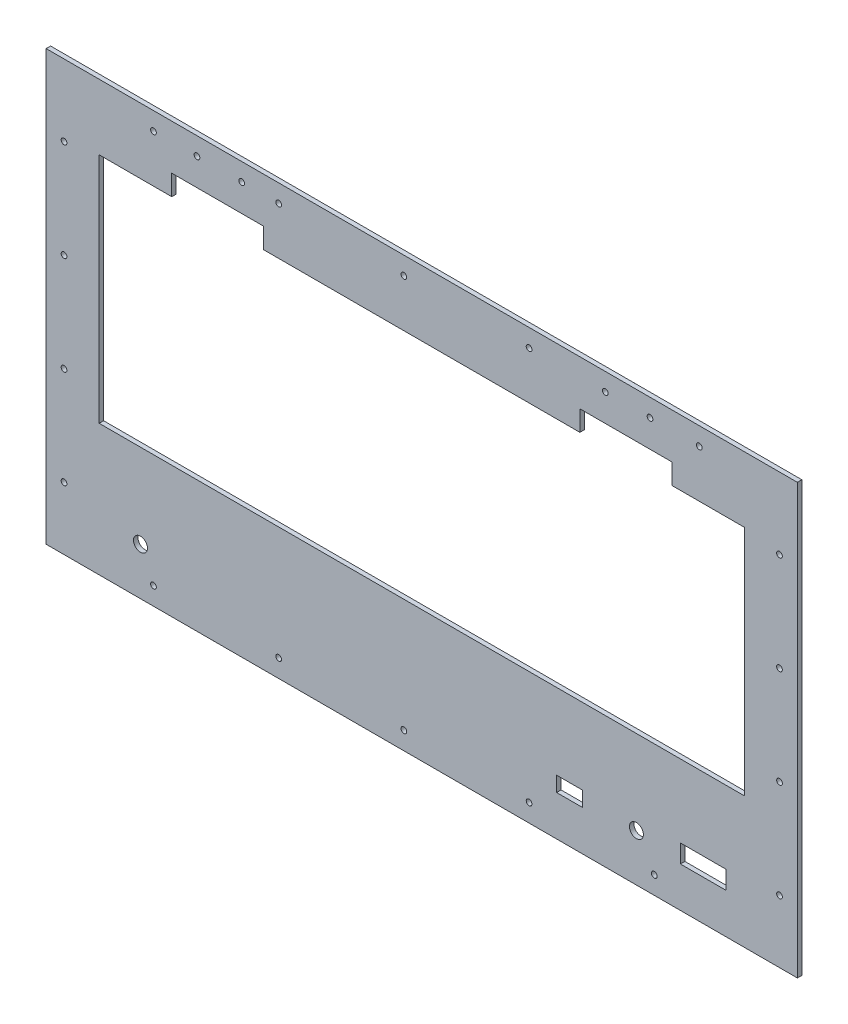
from build123d import *

# Parameters (mm, degrees)
SKETCH1_W           = 533.4
SKETCH1_H           = 304.8
BOSS_EXTRUDE1_DEPTH = 3.175
SKETCH5_R           = 2.032
CUT_EXTRUDE4_DEPTH  = 4.175
SKETCH6_R           = 2.032
CUT_EXTRUDE5_DEPTH  = 3.175
SKETCH7_R           = 2.032
CUT_EXTRUDE6_DEPTH  = 4.175
SKETCH8_W           = 458.193815808
SKETCH8_H           = 165.1
SKETCH8_W_2         = 65.278
SKETCH8_H_2         = 14.478
CUT_EXTRUDE7_DEPTH  = 4.175
SKETCH9_R           = 4.953
SKETCH9_W           = 32.258
SKETCH9_H           = 12.954
SKETCH9_W_2         = 18.542
SKETCH9_H_2         = 10.668
CUT_EXTRUDE8_DEPTH  = 4.175


with BuildPart() as part:
    # Sketch1 → Boss-Extrude1 (new body)
    with BuildSketch(Plane.XY):
        with Locations((266.7, 152.4)):
            Rectangle(SKETCH1_W, SKETCH1_H)
    extrude(amount=BOSS_EXTRUDE1_DEPTH)

    # Sketch5 → Cut-Extrude4 (cut, through all)
    with BuildSketch(Plane.XY.offset(3.175)):
        with Locations((76.2, 12.7)):
            Circle(SKETCH5_R)
        with Locations((165.1, 12.7)):
            Circle(SKETCH5_R)
        with Locations((254, 12.7)):
            Circle(SKETCH5_R)
        with Locations((342.9, 12.7)):
            Circle(SKETCH5_R)
        with Locations((431.8, 12.7)):
            Circle(SKETCH5_R)
        with Locations((342.9, 292.1)):
            Circle(SKETCH5_R)
        with Locations((254, 292.1)):
            Circle(SKETCH5_R)
        with Locations((165.1, 292.1)):
            Circle(SKETCH5_R)
        with Locations((76.2, 292.1)):
            Circle(SKETCH5_R)
        with Locations((463.719540129, 292.1)):
            Circle(SKETCH5_R)
    extrude(amount=-CUT_EXTRUDE4_DEPTH, mode=Mode.SUBTRACT)

    # Sketch6 → Cut-Extrude5 (cut)
    with BuildSketch(Plane.XY.offset(3.175)):
        with Locations((12.7, 254)):
            Circle(SKETCH6_R)
        with Locations((12.7, 184.15)):
            Circle(SKETCH6_R)
        with Locations((12.7, 114.3)):
            Circle(SKETCH6_R)
        with Locations((12.7, 44.45)):
            Circle(SKETCH6_R)
        with Locations((520.7, 44.45)):
            Circle(SKETCH6_R)
        with Locations((520.7, 114.3)):
            Circle(SKETCH6_R)
        with Locations((520.7, 184.15)):
            Circle(SKETCH6_R)
        with Locations((520.7, 254)):
            Circle(SKETCH6_R)
    extrude(amount=-CUT_EXTRUDE5_DEPTH, mode=Mode.SUBTRACT)

    # Sketch7 → Cut-Extrude6 (cut, through all)
    with BuildSketch(Plane(origin=(0, 0, 0), x_dir=(-1, 0, 0), z_dir=(0, 0, -1))):
        with Locations((-138.857978908, 292.182920205)):
            Circle(SKETCH7_R)
        with Locations((-107.107978908, 292.182920205)):
            Circle(SKETCH7_R)
        with Locations((-428.774184192, 292.182920205)):
            Circle(SKETCH7_R)
        with Locations((-397.024184192, 292.182920205)):
            Circle(SKETCH7_R)
    extrude(amount=-CUT_EXTRUDE6_DEPTH, mode=Mode.SUBTRACT)

    # Sketch8 → Cut-Extrude7 (cut, through all)
    with BuildSketch(Plane.XY.offset(3.175)):
        with Locations((266.711092096, 175.755983959)):
            Rectangle(SKETCH8_W, SKETCH8_H)
        with Locations((121.815184192, 265.544983959)):
            Rectangle(SKETCH8_W_2, SKETCH8_H_2)
        with Locations((411.607, 265.544983959)):
            Rectangle(SKETCH8_W_2, SKETCH8_H_2)
    extrude(amount=-CUT_EXTRUDE7_DEPTH, mode=Mode.SUBTRACT)

    # Sketch9 → Cut-Extrude8 (cut, through all)
    with BuildSketch(Plane.XY.offset(3.175)):
        with Locations((419.1, 33.528)):
            Circle(SKETCH9_R)
        with Locations((66.977757166, 33.528)):
            Circle(SKETCH9_R)
        with Locations((466.471, 35.052)):
            Rectangle(SKETCH9_W, SKETCH9_H)
        with Locations((371.729, 33.909)):
            Rectangle(SKETCH9_W_2, SKETCH9_H_2)
    extrude(amount=-CUT_EXTRUDE8_DEPTH, mode=Mode.SUBTRACT)


solid = part.part
